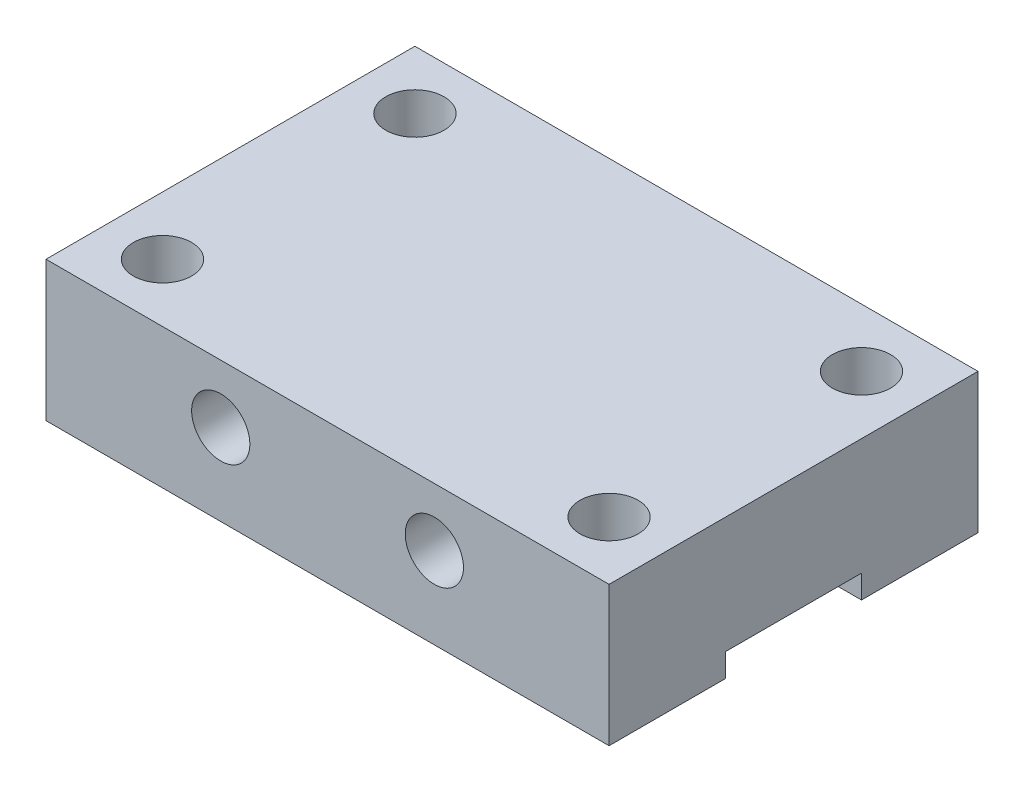
from build123d import *

# Parameters (mm, degrees)
BOSS_EXTRUDE1_DEPTH = 19
BOSS_EXTRUDE2_DEPTH = 7
LPATTERN1_COUNT     = 7
LPATTERN1_PITCH     = 2
LPATTERN1_COL_COUNT = 7
LPATTERN1_COL_PITCH = 2
SKETCH8_R           = 1.5
CUT_EXTRUDE1_DEPTH  = 19
SKETCH11_W          = 29
SKETCH11_H          = 6
BOSS_EXTRUDE3_DEPTH = 1.2
SKETCH9_R           = 1.5
CUT_EXTRUDE2_DEPTH  = 7.2


with BuildPart() as part:
    # Sketch2 → Boss-Extrude1 (new body)
    with BuildSketch(Plane.XY):
        Polygon((43, -6), (72, -6), (72, 0), (57.5, 0), (43, 0), align=None)
    extrude(amount=BOSS_EXTRUDE1_DEPTH)

    # Sketch4 → Boss-Extrude2 (add)
    with BuildSketch(Plane.XY.offset(13)):
        Polygon((57.5, -6.8), (57.3, -6.8), (56.5, -5.2), (57.5, -5.2), (58.5, -5.2), (57.7, -6.8), align=None)
    boss_extrude2 = extrude(amount=-BOSS_EXTRUDE2_DEPTH)

    # LPattern1: Boss-Extrude2 ×7
    with Locations(*[(i * LPATTERN1_PITCH, 0, 0) for i in range(1, LPATTERN1_COUNT)]):
        add(boss_extrude2)

    # LPattern1 col: Boss-Extrude2 ×7
    with Locations(*[(-i * LPATTERN1_COL_PITCH, 0, 0) for i in range(1, LPATTERN1_COL_COUNT)]):
        add(boss_extrude2)

    # Sketch8 → Cut-Extrude1 (cut)
    with BuildSketch(Plane.XY.offset(19)):
        with Locations((52, -3)):
            Circle(SKETCH8_R)
        with Locations((63, -3)):
            Circle(SKETCH8_R)
    extrude(amount=-CUT_EXTRUDE1_DEPTH, mode=Mode.SUBTRACT)

    # Sketch11 → Boss-Extrude3 (add)
    with BuildSketch(Plane.XZ.offset(6)):
        with Locations((57.5, 16)):
            Rectangle(SKETCH11_W, SKETCH11_H)
        with Locations((57.5, 3)):
            Rectangle(SKETCH11_W, SKETCH11_H)
    extrude(amount=BOSS_EXTRUDE3_DEPTH)

    # Sketch9 → Cut-Extrude2 (cut)
    with BuildSketch(Plane.XZ.offset(7.2)):
        with Locations((69, 16)):
            Circle(SKETCH9_R)
        with Locations((69, 3)):
            Circle(SKETCH9_R)
        with Locations((46, 3)):
            Circle(SKETCH9_R)
        with Locations((46, 16)):
            Circle(SKETCH9_R)
    extrude(amount=-CUT_EXTRUDE2_DEPTH, mode=Mode.SUBTRACT)


solid = part.part
